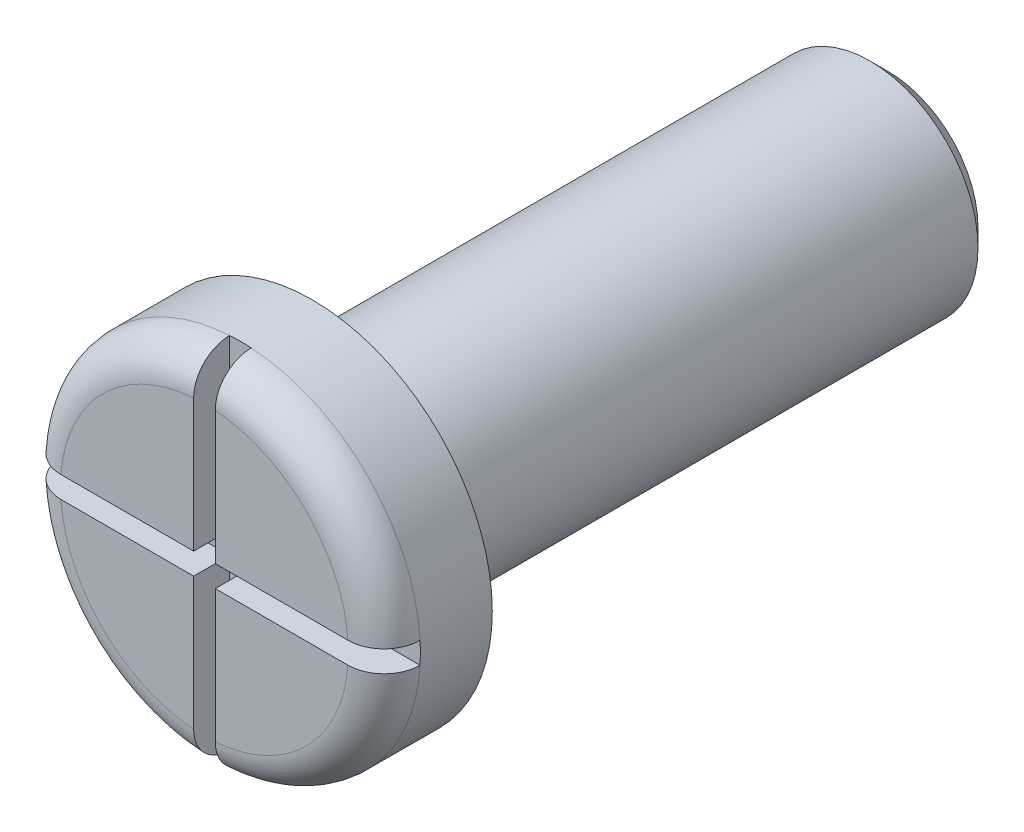
from build123d import *

# Parameters (mm, degrees)
CHAMFER1_SIZE      = 0.25
CUT_EXTRUDE1_DEPTH = 0.5
FILLET7_R          = 0.5


with BuildPart() as part:
    # Sketch1 → Revolve1 (revolve)
    with BuildSketch(Plane(origin=(0, 0, 0), x_dir=(0, 0, -1), z_dir=(1, 0, 0))):
        Polygon((9.5, 0), (9.5, 1.5), (1.5, 1.5), (1.5, 2.5), (0, 2.5), (0, 0), align=None)
    revolve(axis=Axis((0, 0, 0), (0, 0, -1)))

    # Chamfer1
    chamfer1_edges = [part.edges().sort_by_distance(p)[0] for p in [
        (0, -1.5, -9.5),
    ]]
    chamfer(chamfer1_edges, length=CHAMFER1_SIZE)

    # Sketch2 → Cut-Extrude1 (cut)
    with BuildSketch(Plane.XY):
        with BuildLine():
            Line((-0.15, 2.495495943), (-0.15, 0.15))
            Line((-0.15, 0.15), (-2.495495943, 0.15))
            ThreePointArc((-2.495495943, 0.15), (-2.5, 0), (-2.495495943, -0.15))
            Line((-2.495495943, -0.15), (-0.15, -0.15))
            Line((-0.15, -0.15), (-0.15, -2.495495943))
            ThreePointArc((-0.15, -2.495495943), (0, -2.5), (0.15, -2.495495943))
            Line((0.15, -2.495495943), (0.15, -0.15))
            Line((0.15, -0.15), (2.495495943, -0.15))
            ThreePointArc((2.495495943, -0.15), (2.5, 0), (2.495495943, 0.15))
            Line((2.495495943, 0.15), (0.15, 0.15))
            Line((0.15, 0.15), (0.15, 2.495495943))
            ThreePointArc((0.15, 2.495495943), (0, 2.5), (-0.15, 2.495495943))
        make_face()
    extrude(amount=-CUT_EXTRUDE1_DEPTH, mode=Mode.SUBTRACT)

    # Fillet7
    fillet7_edges = [part.edges().sort_by_distance(p)[0] for p in [
        (-1.767766953, -1.767766953, 0),
        (1.767766953, -1.767766953, 0),
        (1.767766953, 1.767766953, 0),
        (-1.767766953, 1.767766953, 0),
    ]]
    fillet(fillet7_edges, radius=FILLET7_R)


solid = part.part
